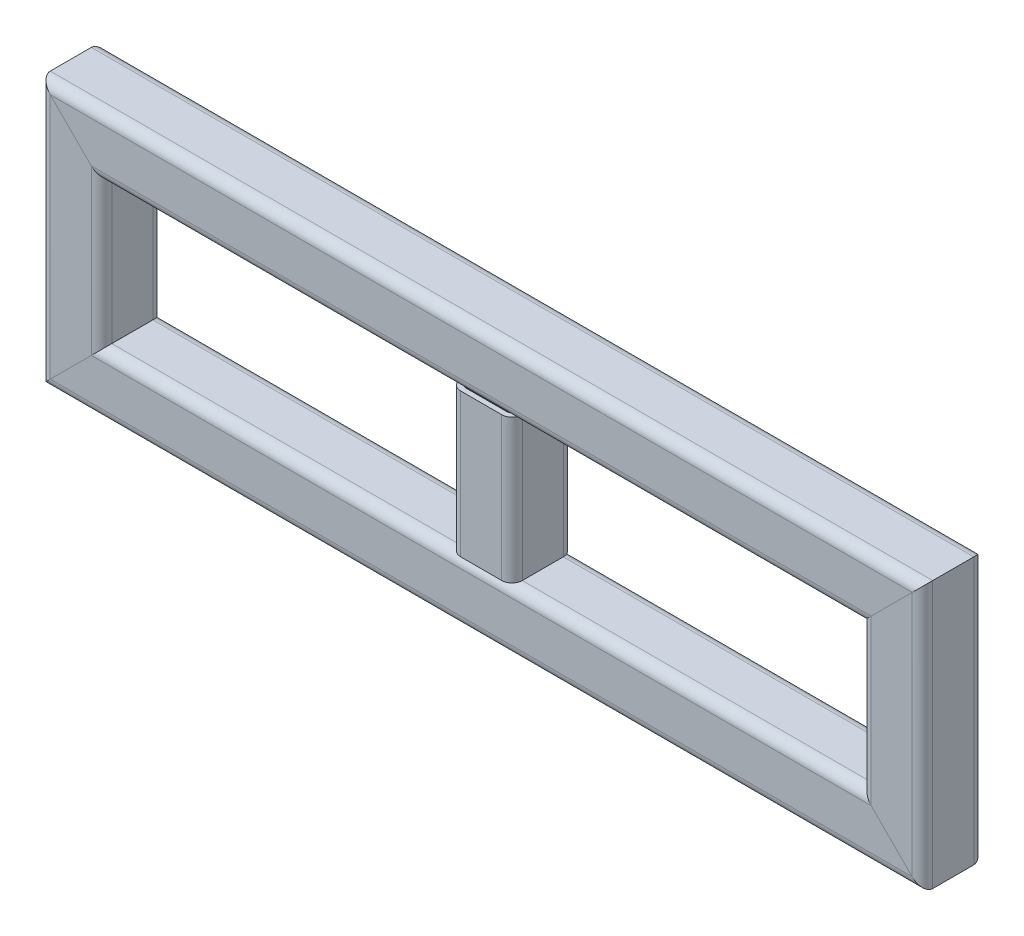
from build123d import *

# Parameters (mm, degrees)
STRUCTURAL_MEMBER1_DEPTH      = 154.940768363
STRUCTURAL_MEMBER1_DEPTH_BACK = 27.940768363
STRUCTURAL_MEMBER1_2_DEPTH    = 563.881536726
STRUCTURAL_MEMBER1_3_DEPTH    = 182.881536726
STRUCTURAL_MEMBER1_4_DEPTH    = 563.881536726
STRUCTURAL_MEMBER1_5_DEPTH    = 129


with BuildPart() as part:
    # Sketch1 → Structural Member1 (new, two sides)
    with BuildSketch(Plane(origin=(67.848170594, 155.581975946, 0), x_dir=(1, 0, 0), z_dir=(0, -1, 0))) as structural_member1_sk:
        with BuildLine():
            Line((-12.7, -19.05), (12.7, -19.05))
            ThreePointArc((12.7, -19.05), (17.190128061, -17.190128061), (19.05, -12.7))
            Line((19.05, -12.7), (19.05, 12.7))
            ThreePointArc((19.05, 12.7), (17.190128061, 17.190128061), (12.7, 19.05))
            Line((12.7, 19.05), (-12.7, 19.05))
            ThreePointArc((-12.7, 19.05), (-17.190128061, 17.190128061), (-19.05, 12.7))
            Line((-19.05, 12.7), (-19.05, -12.7))
            ThreePointArc((-19.05, -12.7), (-17.190128061, -17.190128061), (-12.7, -19.05))
        make_face()
        with BuildLine():
            Line((-12.7, -15.875), (12.7, -15.875))
            ThreePointArc((12.7, -15.875), (14.94506403, -14.94506403), (15.875, -12.7))
            Line((15.875, -12.7), (15.875, 12.7))
            ThreePointArc((15.875, 12.7), (14.94506403, 14.94506403), (12.7, 15.875))
            Line((12.7, 15.875), (-12.7, 15.875))
            ThreePointArc((-12.7, 15.875), (-14.94506403, 14.94506403), (-15.875, 12.7))
            Line((-15.875, 12.7), (-15.875, -12.7))
            ThreePointArc((-15.875, -12.7), (-14.94506403, -14.94506403), (-12.7, -15.875))
        make_face(mode=Mode.SUBTRACT)
    extrude(amount=STRUCTURAL_MEMBER1_DEPTH)
    extrude(structural_member1_sk.sketch, amount=-STRUCTURAL_MEMBER1_DEPTH_BACK)

    # Structural Member1 mitre 1
    split(bisect_by=Plane(origin=(67.848170594, 155.581975946, 0), x_dir=(0.707106781, -0.707106781, 0), z_dir=(-0.707106781, -0.707106781, 0)), keep=Keep.TOP)

    # Structural Member1 mitre 2
    split(bisect_by=Plane(origin=(67.848170594, 28.581975946, 0), x_dir=(-0.707106781, -0.707106781, 0), z_dir=(-0.707106781, 0.707106781, 0)), keep=Keep.TOP)


with BuildPart() as body_2:
    # Sketch1 on segment 2 (carried to segment 2) → Structural Member1 2 (new body)
    with BuildSketch(Plane(origin=(39.907402231, 28.581975946, 0), x_dir=(0, 1, 0), z_dir=(1, 0, 0))):
        with BuildLine():
            Line((-12.7, -19.05), (12.7, -19.05))
            ThreePointArc((12.7, -19.05), (17.190128061, -17.190128061), (19.05, -12.7))
            Line((19.05, -12.7), (19.05, 12.7))
            ThreePointArc((19.05, 12.7), (17.190128061, 17.190128061), (12.7, 19.05))
            Line((12.7, 19.05), (-12.7, 19.05))
            ThreePointArc((-12.7, 19.05), (-17.190128061, 17.190128061), (-19.05, 12.7))
            Line((-19.05, 12.7), (-19.05, -12.7))
            ThreePointArc((-19.05, -12.7), (-17.190128061, -17.190128061), (-12.7, -19.05))
        make_face()
        with BuildLine():
            Line((-12.7, -15.875), (12.7, -15.875))
            ThreePointArc((12.7, -15.875), (14.94506403, -14.94506403), (15.875, -12.7))
            Line((15.875, -12.7), (15.875, 12.7))
            ThreePointArc((15.875, 12.7), (14.94506403, 14.94506403), (12.7, 15.875))
            Line((12.7, 15.875), (-12.7, 15.875))
            ThreePointArc((-12.7, 15.875), (-14.94506403, 14.94506403), (-15.875, 12.7))
            Line((-15.875, 12.7), (-15.875, -12.7))
            ThreePointArc((-15.875, -12.7), (-14.94506403, -14.94506403), (-12.7, -15.875))
        make_face(mode=Mode.SUBTRACT)
    extrude(amount=STRUCTURAL_MEMBER1_2_DEPTH)

    # Structural Member1 2 mitre 1
    split(bisect_by=Plane(origin=(67.848170594, 28.581975946, 0), x_dir=(0.707106781, 0.707106781, 0), z_dir=(0.707106781, -0.707106781, 0)), keep=Keep.TOP)

    # Structural Member1 2 mitre 2
    split(bisect_by=Plane(origin=(575.848170594, 28.581975946, 0), x_dir=(0.707106781, -0.707106781, 0), z_dir=(-0.707106781, -0.707106781, 0)), keep=Keep.TOP)


with BuildPart() as body_3:
    # Sketch1 on segment 3 (carried to segment 3) → Structural Member1 3 (new body)
    with BuildSketch(Plane(origin=(575.848170594, 0.641207582, 0), x_dir=(-1, 0, 0), z_dir=(0, 1, 0))):
        with BuildLine():
            Line((-12.7, -19.05), (12.7, -19.05))
            ThreePointArc((12.7, -19.05), (17.190128061, -17.190128061), (19.05, -12.7))
            Line((19.05, -12.7), (19.05, 12.7))
            ThreePointArc((19.05, 12.7), (17.190128061, 17.190128061), (12.7, 19.05))
            Line((12.7, 19.05), (-12.7, 19.05))
            ThreePointArc((-12.7, 19.05), (-17.190128061, 17.190128061), (-19.05, 12.7))
            Line((-19.05, 12.7), (-19.05, -12.7))
            ThreePointArc((-19.05, -12.7), (-17.190128061, -17.190128061), (-12.7, -19.05))
        make_face()
        with BuildLine():
            Line((-12.7, -15.875), (12.7, -15.875))
            ThreePointArc((12.7, -15.875), (14.94506403, -14.94506403), (15.875, -12.7))
            Line((15.875, -12.7), (15.875, 12.7))
            ThreePointArc((15.875, 12.7), (14.94506403, 14.94506403), (12.7, 15.875))
            Line((12.7, 15.875), (-12.7, 15.875))
            ThreePointArc((-12.7, 15.875), (-14.94506403, 14.94506403), (-15.875, 12.7))
            Line((-15.875, 12.7), (-15.875, -12.7))
            ThreePointArc((-15.875, -12.7), (-14.94506403, -14.94506403), (-12.7, -15.875))
        make_face(mode=Mode.SUBTRACT)
    extrude(amount=STRUCTURAL_MEMBER1_3_DEPTH)

    # Structural Member1 3 mitre 1
    split(bisect_by=Plane(origin=(575.848170594, 155.581975946, 0), x_dir=(0.707106781, 0.707106781, 0), z_dir=(0.707106781, -0.707106781, 0)), keep=Keep.TOP)

    # Structural Member1 3 mitre 2
    split(bisect_by=Plane(origin=(575.848170594, 28.581975946, 0), x_dir=(-0.707106781, 0.707106781, 0), z_dir=(0.707106781, 0.707106781, 0)), keep=Keep.TOP)


with BuildPart() as body_4:
    # Sketch1 on segment 4 (carried to segment 4) → Structural Member1 4 (new body)
    with BuildSketch(Plane(origin=(603.788938957, 155.581975946, 0), x_dir=(0, -1, 0), z_dir=(-1, 0, 0))):
        with BuildLine():
            Line((-12.7, -19.05), (12.7, -19.05))
            ThreePointArc((12.7, -19.05), (17.190128061, -17.190128061), (19.05, -12.7))
            Line((19.05, -12.7), (19.05, 12.7))
            ThreePointArc((19.05, 12.7), (17.190128061, 17.190128061), (12.7, 19.05))
            Line((12.7, 19.05), (-12.7, 19.05))
            ThreePointArc((-12.7, 19.05), (-17.190128061, 17.190128061), (-19.05, 12.7))
            Line((-19.05, 12.7), (-19.05, -12.7))
            ThreePointArc((-19.05, -12.7), (-17.190128061, -17.190128061), (-12.7, -19.05))
        make_face()
        with BuildLine():
            Line((-12.7, -15.875), (12.7, -15.875))
            ThreePointArc((12.7, -15.875), (14.94506403, -14.94506403), (15.875, -12.7))
            Line((15.875, -12.7), (15.875, 12.7))
            ThreePointArc((15.875, 12.7), (14.94506403, 14.94506403), (12.7, 15.875))
            Line((12.7, 15.875), (-12.7, 15.875))
            ThreePointArc((-12.7, 15.875), (-14.94506403, 14.94506403), (-15.875, 12.7))
            Line((-15.875, 12.7), (-15.875, -12.7))
            ThreePointArc((-15.875, -12.7), (-14.94506403, -14.94506403), (-12.7, -15.875))
        make_face(mode=Mode.SUBTRACT)
    extrude(amount=STRUCTURAL_MEMBER1_4_DEPTH)

    # Structural Member1 4 mitre 1
    split(bisect_by=Plane(origin=(67.848170594, 155.581975946, 0), x_dir=(-0.707106781, 0.707106781, 0), z_dir=(0.707106781, 0.707106781, 0)), keep=Keep.TOP)

    # Structural Member1 4 mitre 2
    split(bisect_by=Plane(origin=(575.848170594, 155.581975946, 0), x_dir=(-0.707106781, -0.707106781, 0), z_dir=(-0.707106781, 0.707106781, 0)), keep=Keep.TOP)


with BuildPart() as body_5:
    # Sketch1 on segment 5 (carried to segment 5) → Structural Member1 5 (new body)
    with BuildSketch(Plane(origin=(321.848170594, 156.581975946, 0), x_dir=(1, 0, 0), z_dir=(0, -1, 0))):
        with BuildLine():
            Line((-12.7, -19.05), (12.7, -19.05))
            ThreePointArc((12.7, -19.05), (17.190128061, -17.190128061), (19.05, -12.7))
            Line((19.05, -12.7), (19.05, 12.7))
            ThreePointArc((19.05, 12.7), (17.190128061, 17.190128061), (12.7, 19.05))
            Line((12.7, 19.05), (-12.7, 19.05))
            ThreePointArc((-12.7, 19.05), (-17.190128061, 17.190128061), (-19.05, 12.7))
            Line((-19.05, 12.7), (-19.05, -12.7))
            ThreePointArc((-19.05, -12.7), (-17.190128061, -17.190128061), (-12.7, -19.05))
        make_face()
        with BuildLine():
            Line((-12.7, -15.875), (12.7, -15.875))
            ThreePointArc((12.7, -15.875), (14.94506403, -14.94506403), (15.875, -12.7))
            Line((15.875, -12.7), (15.875, 12.7))
            ThreePointArc((15.875, 12.7), (14.94506403, 14.94506403), (12.7, 15.875))
            Line((12.7, 15.875), (-12.7, 15.875))
            ThreePointArc((-12.7, 15.875), (-14.94506403, 14.94506403), (-15.875, 12.7))
            Line((-15.875, 12.7), (-15.875, -12.7))
            ThreePointArc((-15.875, -12.7), (-14.94506403, -14.94506403), (-12.7, -15.875))
        make_face(mode=Mode.SUBTRACT)
    extrude(amount=STRUCTURAL_MEMBER1_5_DEPTH)

    # Structural Member1 5 mitre 1
    split(bisect_by=Plane(origin=(321.848170594, 136.531975946, 0), x_dir=(1, 0, 0), z_dir=(0, -1, 0)), keep=Keep.TOP)

    # Structural Member1 5 mitre 2
    split(bisect_by=Plane(origin=(321.848170594, 47.631975946, 0), x_dir=(-1, 0, 0), z_dir=(0, 1, 0)), keep=Keep.TOP)


solid = Compound([part.part, body_2.part, body_3.part, body_4.part, body_5.part])
